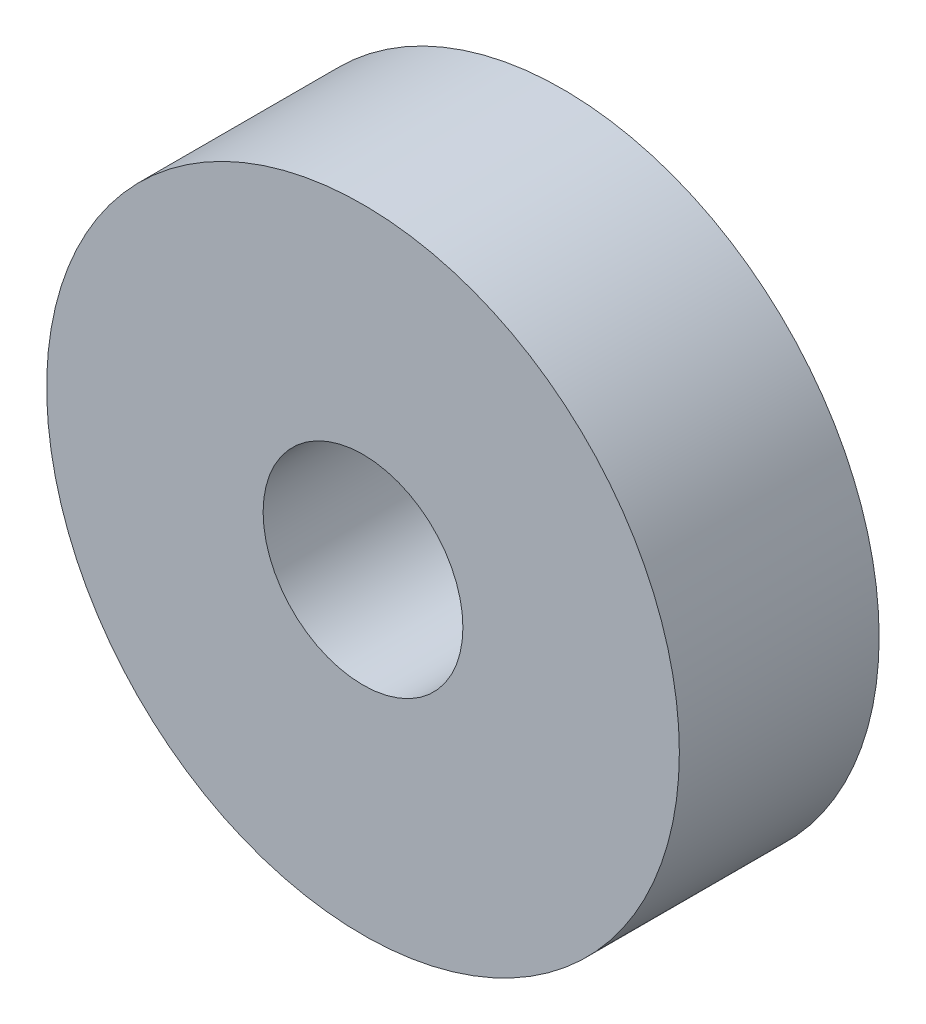
from build123d import *

# Parameters (mm, degrees)
ESQUISSE1_R      = 9.5
ESQUISSE1_R_2    = 3
EXTRUSION1_DEPTH = 6


with BuildPart() as part:
    # Esquisse1 → Extrusion1 (new body)
    with BuildSketch(Plane.XY):
        Circle(ESQUISSE1_R)
        Circle(ESQUISSE1_R_2, mode=Mode.SUBTRACT)
    extrude(amount=EXTRUSION1_DEPTH)


solid = part.part
